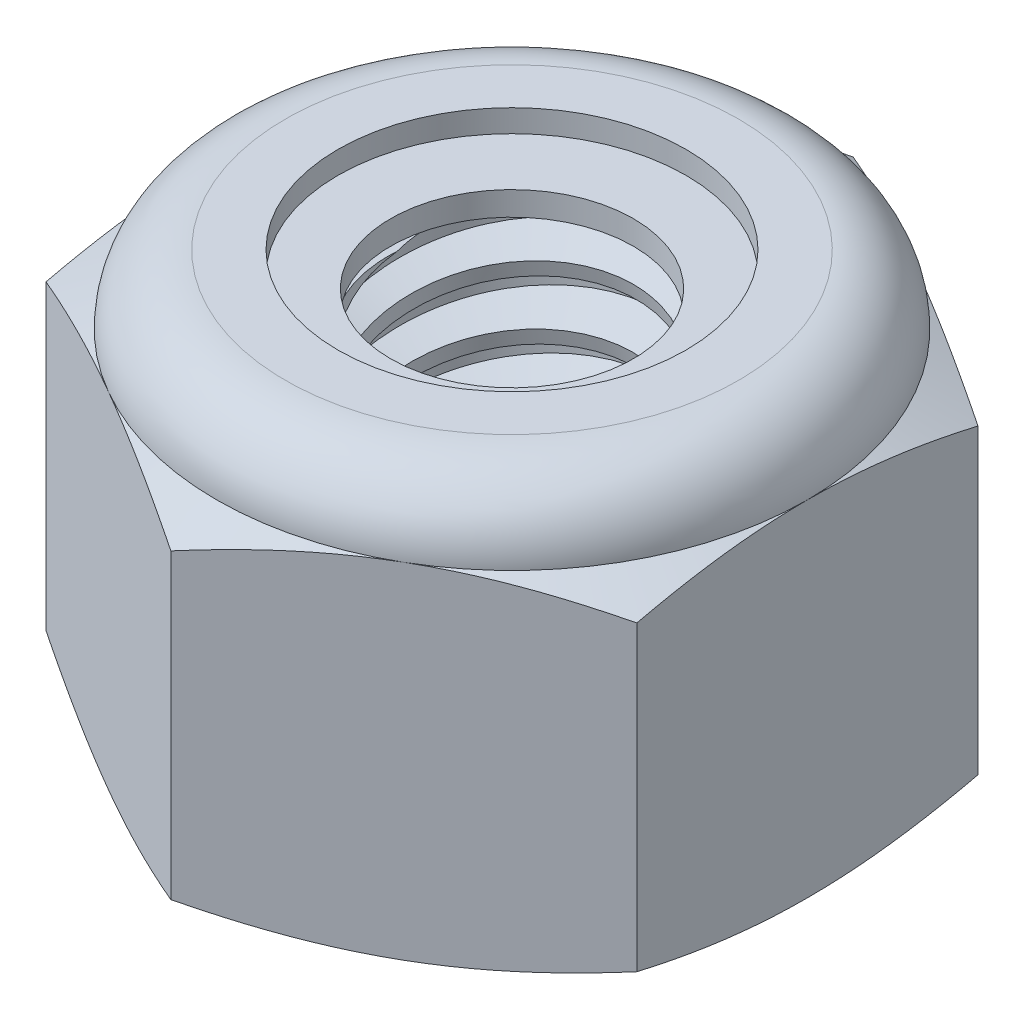
from build123d import *

# Parameters (mm, degrees)
EXTRUDE1_DEPTH      = 2.8
SKETCH2_W           = 1
SKETCH2_H           = 2.8
LPATTERN1_COUNT     = 7
LPATTERN1_PITCH     = 0.4
LPATTERN1_COL_COUNT = 2
LPATTERN1_COL_PITCH = 0.4


with BuildPart() as part:
    # Sketch1 → Extrude1 (new body)
    with BuildSketch(Plane(origin=(0, 0, 0), x_dir=(1, 0, 0), z_dir=(0, 1, 0))):
        Polygon((0, 2.309401077), (-2, 1.154700538), (-2, -1.154700538), (0, -2.309401077), (2, -1.154700538), (2, 1.154700538), align=None)
    extrude(amount=EXTRUDE1_DEPTH)

    # Sketch4 → Cut-Revolve2 (revolve, cut)
    with BuildSketch(Plane(origin=(0, 0, 0), x_dir=(0, 0, -1), z_dir=(1, 0, 0))):
        Polygon((0, 2.8), (1, 2.8), (0.82201838, 2.717005807), (0.82201838, 0.082994193), (1, 0), (0, 0), align=None)
    revolve(axis=Axis((0, 2.8, 0), (0, 1, 0)), mode=Mode.SUBTRACT)


with BuildPart() as body_2:
    # Sketch2 → Revolve1 (revolve)
    with BuildSketch(Plane(origin=(0, 0, 0), x_dir=(0, 0, -1), z_dir=(1, 0, 0))):
        with Locations((0.5, 1.4)):
            Rectangle(SKETCH2_W, SKETCH2_H)
    revolve(axis=Axis((0, -1, 0), (0, 1, 0)))

    # Sketch3 → Cut-Revolve1 (revolve, cut)
    with BuildSketch(Plane(origin=(0, 0, 0), x_dir=(0, 0, -1), z_dir=(1, 0, 0))):
        Polygon((1.009805807, 2.750970966), (1.078446454, 2.40776773), (0.841629993, 2.487879925), (0.82201838, 2.585937993), align=None)
    cut_revolve1 = revolve(axis=Axis((0, 2.8, 0.085891176), (0, -0.980580676, -0.196116135)), mode=Mode.SUBTRACT)

    # LPattern1: Cut-Revolve1 ×7
    with Locations(*[(0, -i * LPATTERN1_PITCH, 0) for i in range(1, LPATTERN1_COUNT)]):
        add(cut_revolve1, mode=Mode.SUBTRACT)

    # LPattern1 col: Cut-Revolve1 ×2
    with Locations(*[(0, i * LPATTERN1_COL_PITCH, 0) for i in range(1, LPATTERN1_COL_COUNT)]):
        add(cut_revolve1, mode=Mode.SUBTRACT)


with BuildPart() as part_1:
    add(part.part)

    # Combine1: cut body 2
    add(body_2.part, mode=Mode.SUBTRACT)

    # Sketch5 → Cut-Revolve3 (revolve, cut)
    with BuildSketch(Plane(origin=(0, 0, 0), x_dir=(0, 0, -1), z_dir=(1, 0, 0))):
        with BuildLine():
            Line((0, 0), (2, 0))
            Line((2, 0), (2.309401077, 0.144276092))
            Line((2.309401077, 0.144276092), (2.309401077, 2.189057242))
            Line((2.309401077, 2.189057242), (2, 2.333333333))
            ThreePointArc((2, 2.333333333), (1.863316498, 2.663316498), (1.533333333, 2.8))
            Line((1.533333333, 2.8), (1.533333333, 4.07))
            Line((1.533333333, 4.07), (3.579401077, 4.07))
            Line((3.579401077, 4.07), (3.579401077, -1.27))
            Line((3.579401077, -1.27), (0, -1.27))
            Line((0, -1.27), (0, 0))
        make_face()
    revolve(axis=Axis((0, 0, 0), (0, 1, 0)), mode=Mode.SUBTRACT)

    # Sketch6 → Cut-Revolve4 (revolve, cut)
    with BuildSketch(Plane(origin=(0, 0, 0), x_dir=(0, 0, -1), z_dir=(1, 0, 0))):
        with BuildLine():
            Line((0, 2.333333333), (1.8476, 2.333333333))
            ThreePointArc((1.8476, 2.333333333), (1.755553424, 2.555553424), (1.533333333, 2.6476))
            Line((1.533333333, 2.6476), (1.177675857, 2.6476))
            Line((1.177675857, 2.6476), (1.177675857, 4.07))
            Line((1.177675857, 4.07), (0, 4.07))
            Line((0, 4.07), (0, 2.333333333))
        make_face()
    revolve(axis=Axis((0, 4.07, 0), (0, 1, 0)), mode=Mode.SUBTRACT)


with BuildPart() as body_2_2:
    # Sketch7 → Revolve2 (revolve)
    with BuildSketch(Plane(origin=(0, 0, 0), x_dir=(0, 0, -1), z_dir=(1, 0, 0))):
        with BuildLine():
            Line((0.82201838, 2.409533333), (1.758875564, 2.409533333))
            ThreePointArc((1.758875564, 2.409533333), (1.672140858, 2.526745352), (1.533333333, 2.5714))
            Line((1.533333333, 2.5714), (0.82201838, 2.5714))
            Line((0.82201838, 2.5714), (0.82201838, 2.409533333))
        make_face()
    revolve(axis=Axis((0, 2.409533333, 0), (0, 1, 0)))


solid = Compound([part_1.part, body_2_2.part])
